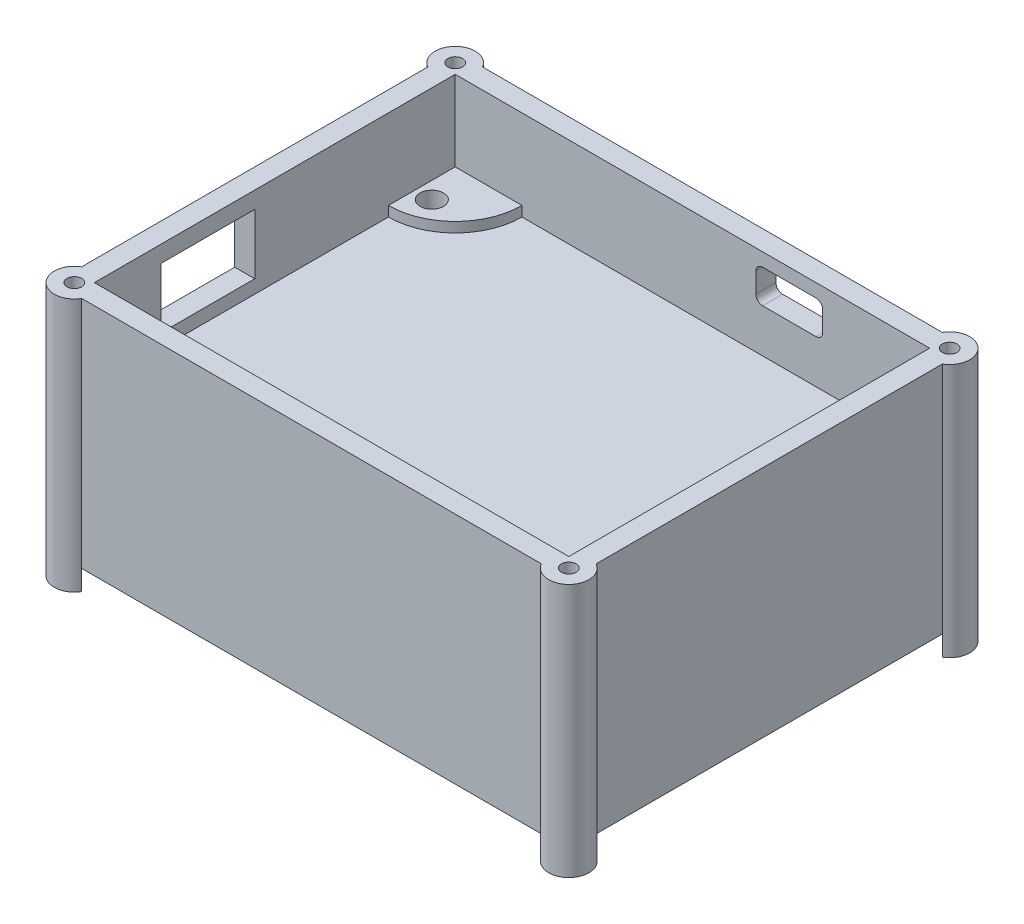
from build123d import *

# Parameters (mm, degrees)
SKETCH1_W           = 77
SKETCH1_H           = 60
SKETCH1_W_2         = 71
SKETCH1_H_2         = 54
SKETCH1_R           = 1.75
BOSS_EXTRUDE1_DEPTH = 45
SKETCH2_R           = 1.75
CUT_EXTRUDE1_DEPTH  = 12
SKETCH3_W           = 77
SKETCH3_H           = 60
SKETCH3_R           = 1.75
BOSS_EXTRUDE2_DEPTH = 3
CUT_EXTRUDE2_DEPTH  = 10
SKETCH6_W           = 14
SKETCH6_H           = 9
CUT_EXTRUDE3_DEPTH  = 10
SKETCH7_R           = 1.1
CUT_EXTRUDE4_DEPTH  = 10
SKETCH9_W           = 60
SKETCH9_H           = 30
CUT_EXTRUDE5_DEPTH  = 169
SKETCH10_W          = 77
SKETCH10_H          = 60
BOSS_EXTRUDE3_DEPTH = 20
BOSS_EXTRUDE4_DEPTH = 1.5
SKETCH13_R          = 3
CUT_EXTRUDE6_DEPTH  = 1.5
FILLET1_R           = 1
BOSS_EXTRUDE5_DEPTH = 38
BOSS_EXTRUDE6_DEPTH = 38


with BuildPart() as part:
    # Sketch1 → Boss-Extrude1 (new body)
    with BuildSketch(Plane(origin=(0, 0, 0), x_dir=(1, 0, 0), z_dir=(0, 1, 0))):
        Rectangle(SKETCH1_W, SKETCH1_H)
        Rectangle(SKETCH1_W_2, SKETCH1_H_2, mode=Mode.SUBTRACT)
        with BuildLine():
            ThreePointArc((-25.5, -27), (-28.428932188, -19.928932188), (-35.5, -17))
            Line((-35.5, -17), (-35.5, -27))
            Line((-35.5, -27), (-25.5, -27))
        make_face()
        with Locations((-33, -23)):
            Circle(SKETCH1_R, mode=Mode.SUBTRACT)
        with BuildLine():
            Line((-25.5, 27), (-35.5, 27))
            Line((-35.5, 27), (-35.5, 17))
            ThreePointArc((-35.5, 17), (-28.428932188, 19.928932188), (-25.5, 27))
        make_face()
        with Locations((-33, 21)):
            Circle(SKETCH1_R, mode=Mode.SUBTRACT)
        with BuildLine():
            Line((35.5, 27), (25.5, 27))
            ThreePointArc((25.5, 27), (28.428932188, 19.928932188), (35.5, 17))
            Line((35.5, 17), (35.5, 27))
        make_face()
        with Locations((33, 21)):
            Circle(SKETCH1_R, mode=Mode.SUBTRACT)
        with BuildLine():
            Line((35.5, -27), (35.5, -17))
            ThreePointArc((35.5, -17), (28.428932188, -19.928932188), (25.5, -27))
            Line((25.5, -27), (35.5, -27))
        make_face()
        with Locations((33, -23)):
            Circle(SKETCH1_R, mode=Mode.SUBTRACT)
    extrude(amount=BOSS_EXTRUDE1_DEPTH)

    # Sketch2 → Cut-Extrude1 (cut)
    with BuildSketch(Plane(origin=(0, 45, 0), x_dir=(1, 0, 0), z_dir=(0, 1, 0))):
        with BuildLine():
            Line((-25.5, 27), (-35.5, 27))
            Line((-35.5, 27), (-35.5, 17))
            ThreePointArc((-35.5, 17), (-28.428932188, 19.928932188), (-25.5, 27))
        make_face()
        with Locations((-33, 21)):
            Circle(SKETCH2_R, mode=Mode.SUBTRACT)
        with BuildLine():
            Line((35.5, 17), (35.5, 27))
            Line((35.5, 27), (25.5, 27))
            ThreePointArc((25.5, 27), (28.428932188, 19.928932188), (35.5, 17))
        make_face()
        with Locations((33, 21)):
            Circle(SKETCH2_R, mode=Mode.SUBTRACT)
        with BuildLine():
            Line((-25.5, -27), (-35.5, -27))
            Line((-35.5, -27), (-35.5, -17))
            ThreePointArc((-35.5, -17), (-28.428932188, -19.928932188), (-25.5, -27))
        make_face()
        with Locations((-33, -23)):
            Circle(SKETCH2_R, mode=Mode.SUBTRACT)
        with BuildLine():
            Line((25.5, -27), (35.5, -27))
            Line((35.5, -27), (35.5, -17))
            ThreePointArc((35.5, -17), (28.428932188, -19.928932188), (25.5, -27))
        make_face()
        with Locations((33, -23)):
            Circle(SKETCH2_R, mode=Mode.SUBTRACT)
    extrude(amount=-CUT_EXTRUDE1_DEPTH, mode=Mode.SUBTRACT)

    # Sketch3 → Boss-Extrude2 (add)
    with BuildSketch(Plane.XZ):
        Rectangle(SKETCH3_W, SKETCH3_H)
        with Locations((33, -21)):
            Circle(SKETCH3_R, mode=Mode.SUBTRACT)
        with Locations((-33, -21)):
            Circle(SKETCH3_R, mode=Mode.SUBTRACT)
        with Locations((33, 23)):
            Circle(SKETCH3_R, mode=Mode.SUBTRACT)
        with Locations((-33, 23)):
            Circle(SKETCH3_R, mode=Mode.SUBTRACT)
    extrude(amount=-BOSS_EXTRUDE2_DEPTH)

    # Sketch4 → Cut-Extrude2 (cut)
    with BuildSketch(Plane(origin=(0, 0, -30), x_dir=(-1, 0, 0), z_dir=(0, 0, -1))):
        with BuildLine():
            Line((-18.5, 43), (-10.5, 43))
            ThreePointArc((-10.5, 43), (-9.792893219, 42.707106781), (-9.5, 42))
            Line((-9.5, 42), (-9.5, 39))
            ThreePointArc((-9.5, 39), (-9.792893219, 38.292893219), (-10.5, 38))
            Line((-10.5, 38), (-18.5, 38))
            ThreePointArc((-18.5, 38), (-19.207106781, 38.292893219), (-19.5, 39))
            Line((-19.5, 39), (-19.5, 42))
            ThreePointArc((-19.5, 42), (-19.207106781, 42.707106781), (-18.5, 43))
        make_face()
    extrude(amount=-CUT_EXTRUDE2_DEPTH, mode=Mode.SUBTRACT)

    # Sketch6 → Cut-Extrude3 (cut)
    with BuildSketch(Plane.ZY.offset(38.5)):
        with Locations((10, 38)):
            Rectangle(SKETCH6_W, SKETCH6_H)
    extrude(amount=-CUT_EXTRUDE3_DEPTH, mode=Mode.SUBTRACT)

    # Sketch7 → Cut-Extrude4 (cut)
    with BuildSketch(Plane(origin=(0, 45, 0), x_dir=(1, 0, 0), z_dir=(0, 1, 0))):
        with Locations((-37, 28.5)):
            Circle(SKETCH7_R)
        with Locations((37, 28.5)):
            Circle(SKETCH7_R)
        with Locations((37, -28.5)):
            Circle(SKETCH7_R)
        with Locations((-37, -28.5)):
            Circle(SKETCH7_R)
    extrude(amount=-CUT_EXTRUDE4_DEPTH, mode=Mode.SUBTRACT)

    # Sketch9 → Cut-Extrude5 (cut)
    with BuildSketch(Plane.ZY.offset(38.5)):
        with Locations((0, 15)):
            Rectangle(SKETCH9_W, SKETCH9_H)
    extrude(amount=-CUT_EXTRUDE5_DEPTH, mode=Mode.SUBTRACT)

    # Sketch10 → Boss-Extrude3 (add)
    with BuildSketch(Plane.XZ.offset(-30)):
        Rectangle(SKETCH10_W, SKETCH10_H)
        Polygon((-35.5, 17), (-35.5, 27), (-25.5, 27), (25.5, 27), (35.5, 27), (35.5, 17), (35.5, -17), (35.5, -27), (25.5, -27), (-25.5, -27), (-35.5, -27), (-35.5, -17), align=None, mode=Mode.SUBTRACT)
    extrude(amount=BOSS_EXTRUDE3_DEPTH)

    # Sketch11 → Boss-Extrude4 (add)
    with BuildSketch(Plane.XZ.offset(-30)):
        with BuildLine():
            Line((35.5, 17), (35.5, -17))
            ThreePointArc((35.5, -17), (28.428932188, -19.928932188), (25.5, -27))
            Line((25.5, -27), (-25.5, -27))
            ThreePointArc((-25.5, -27), (-28.428932188, -19.928932188), (-35.5, -17))
            Line((-35.5, -17), (-35.5, 17))
            ThreePointArc((-35.5, 17), (-28.428932188, 19.928932188), (-25.5, 27))
            Line((-25.5, 27), (25.5, 27))
            ThreePointArc((25.5, 27), (28.428932188, 19.928932188), (35.5, 17))
        make_face()
    extrude(amount=-BOSS_EXTRUDE4_DEPTH)

    # Sketch13 → Cut-Extrude6 (cut)
    with BuildSketch(Plane.XZ.offset(-30)):
        with Locations((22.535934278, 21.73153163)):
            Circle(SKETCH13_R)
    extrude(amount=-CUT_EXTRUDE6_DEPTH, mode=Mode.SUBTRACT)

    # Fillet1
    fillet1_edges = [part.edges().sort_by_distance(p)[0] for p in [
        (38.5, 27.5, 30),
        (-38.5, 27.5, 30),
        (-38.5, 27.5, -30),
        (38.5, 27.5, -30),
    ]]
    fillet(fillet1_edges, radius=FILLET1_R)

    # Sketch14 → Boss-Extrude5 (add)
    with BuildSketch(Plane(origin=(0, 45, 0), x_dir=(1, 0, 0), z_dir=(0, 1, 0))):
        with BuildLine():
            Line((-38.5, 29), (-38.5, 25.901923789))
            ThreePointArc((-38.5, 25.901923789), (-39.121320344, 30.621320344), (-34.401923789, 30))
            Line((-34.401923789, 30), (-37.5, 30))
            ThreePointArc((-37.5, 30), (-38.207106781, 29.707106781), (-38.5, 29))
        make_face()
    extrude(amount=-BOSS_EXTRUDE5_DEPTH)

    # Sketch15 → Boss-Extrude6 (add)
    with BuildSketch(Plane(origin=(0, 45, 0), x_dir=(1, 0, 0), z_dir=(0, 1, 0))):
        with BuildLine():
            Line((38.5, 29), (38.5, 25.901923789))
            ThreePointArc((38.5, 25.901923789), (39.121320344, 30.621320344), (34.401923789, 30))
            Line((34.401923789, 30), (37.5, 30))
            ThreePointArc((37.5, 30), (38.207106781, 29.707106781), (38.5, 29))
        make_face()
        with BuildLine():
            Line((37.5, -30), (34.401923789, -30))
            ThreePointArc((34.401923789, -30), (39.121320344, -30.621320344), (38.5, -25.901923789))
            Line((38.5, -25.901923789), (38.5, -29))
            ThreePointArc((38.5, -29), (38.207106781, -29.707106781), (37.5, -30))
        make_face()
        with BuildLine():
            ThreePointArc((-38.5, -25.901923789), (-39.121320344, -30.621320344), (-34.401923789, -30))
            Line((-34.401923789, -30), (-37.5, -30))
            ThreePointArc((-37.5, -30), (-38.207106781, -29.707106781), (-38.5, -29))
            Line((-38.5, -29), (-38.5, -25.901923789))
        make_face()
    extrude(amount=-BOSS_EXTRUDE6_DEPTH)


solid = part.part
